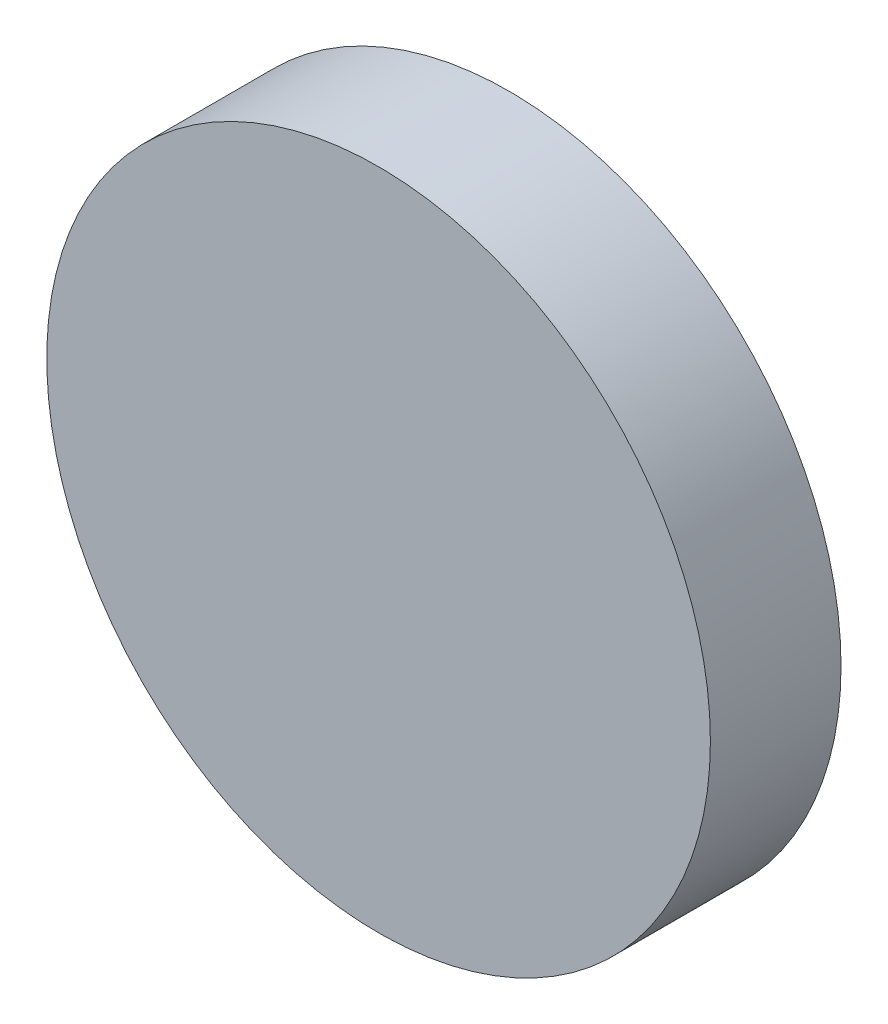
from build123d import *

# Parameters (mm, degrees)
SKETCH1_R           = 20
BOSS_EXTRUDE1_DEPTH = 7.874


with BuildPart() as part:
    # Sketch1 → Boss-Extrude1 (new body)
    with BuildSketch(Plane.XY):
        Circle(SKETCH1_R)
    extrude(amount=BOSS_EXTRUDE1_DEPTH)


solid = part.part
